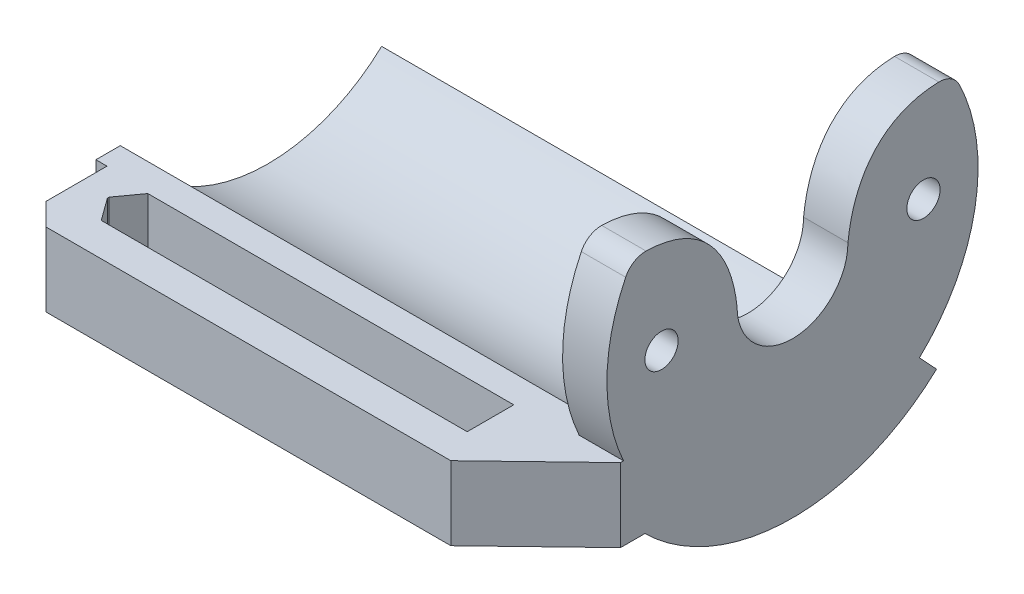
from build123d import *

# Parameters (mm, degrees)
SKETCH2_R                = 1.905
BOSS_EXTRUDE1_DEPTH      = 5.08
BOSS_EXTRUDE2_DEPTH      = 55
BOSS_EXTRUDE2_DEPTH_BACK = 5.08
SKETCH6_W                = 60.08
SKETCH6_H                = 8.434755733
BOSS_EXTRUDE3_DEPTH      = 2.794
BOSS_EXTRUDE4_DEPTH      = 8.434756
CHAMFER1_SIZE            = 2.54


with BuildPart() as part:
    # Sketch2 → Boss-Extrude1 (new body)
    with BuildSketch(Plane(origin=(0, 0, 0), x_dir=(0, 0, -1), z_dir=(1, 0, 0))):
        with BuildLine():
            ThreePointArc((6.35, 0), (0, -6.35), (-6.35, 0))
            add(Edge.make_bspline(
                [(-16.765082275, 10.732202813), (-10.995197474, 10.605430611), (-7.093707097, 6.823689801), (-6.35, 0)],
                knots=[0.082134521, 0.082134521, 0.082134521, 0.082134521, 1, 1, 1, 1], degree=3))
            ThreePointArc((-16.765082275, 10.732202813), (-18.143717665, 10.361153764), (-19.104415619, 9.30504185))
            ThreePointArc((-19.104415619, 9.30504185), (-20.706657527, 4.774603025), (-21.25, 0))
            ThreePointArc((-21.25, 0), (0, -21.25), (21.25, 0))
            ThreePointArc((21.25, 0), (20.706657527, 4.774603025), (19.104415619, 9.30504185))
            ThreePointArc((19.104415619, 9.30504185), (18.143717665, 10.361153764), (16.765082275, 10.732202813))
            add(Edge.make_bspline(
                [(16.765082275, 10.732202813), (10.995197474, 10.605430611), (7.093707097, 6.823689801), (6.35, 0)],
                knots=[0.082134521, 0.082134521, 0.082134521, 0.082134521, 1, 1, 1, 1], degree=3))
        make_face()
        with Locations((-15, 0)):
            Circle(SKETCH2_R, mode=Mode.SUBTRACT)
        with Locations((15, 0)):
            Circle(SKETCH2_R, mode=Mode.SUBTRACT)
    extrude(amount=BOSS_EXTRUDE1_DEPTH)

    # Sketch3 → Boss-Extrude2 (add, two sides)
    with BuildSketch(Plane.ZY) as boss_extrude2_sk:
        with BuildLine():
            ThreePointArc((16.903112003, -12.878171633), (1.771236823, -21.176052987), (-14.528859308, -15.507248215))
            Line((-14.528859308, -15.507248215), (-16.497947063, -17.608936444))
            ThreePointArc((-16.497947063, -17.608936444), (0.280682132, -24.128367486), (16.903112003, -17.220386309))
            Line((16.903112003, -17.220386309), (16.903112003, -12.878171633))
        make_face()
        with BuildLine():
            ThreePointArc((16.903112003, -8.785630576), (3.210032128, -18.777598189), (-13.02469505, -13.90179193))
            Line((-13.02469505, -13.90179193), (-14.528859308, -15.507248215))
            ThreePointArc((-14.528859308, -15.507248215), (1.771236823, -21.176052987), (16.903112003, -12.878171633))
            Line((16.903112003, -12.878171633), (16.903112003, -8.785630576))
        make_face()
    extrude(amount=BOSS_EXTRUDE2_DEPTH)
    extrude(boss_extrude2_sk.sketch, amount=-BOSS_EXTRUDE2_DEPTH_BACK)

    # Sketch6 → Boss-Extrude3 (add)
    with BuildSketch(Plane.XY.offset(16.903112003)):
        with Locations((-24.96, -13.003008443)):
            Rectangle(SKETCH6_W, SKETCH6_H)
    extrude(amount=BOSS_EXTRUDE3_DEPTH)

    # Sketch7 → Boss-Extrude4 (add)
    with BuildSketch(Plane(origin=(0, -8.785630576, 0), x_dir=(1, 0, 0), z_dir=(0, 1, 0))):
        Polygon((-53.728777932, -19.697112003), (-53.728777932, -29.222112003), (-4.829590455, -29.222112003), (5.08, -19.697112003), align=None)
        Polygon((-50.534168456, -22.645679195), (-48.67304704, -20.078112003), (-6.76304704, -20.078112003), (-6.76304704, -25.412112003), (-48.67304704, -25.412112003), (-50.534168456, -22.84454481), align=None, mode=Mode.SUBTRACT)
    extrude(amount=-BOSS_EXTRUDE4_DEPTH)

    # Chamfer1
    chamfer1_edges = [part.edges().sort_by_distance(p)[0] for p in [
        (-53.728777932, -13.003008576, 29.222112003),
    ]]
    chamfer(chamfer1_edges, length=CHAMFER1_SIZE)


solid = part.part
